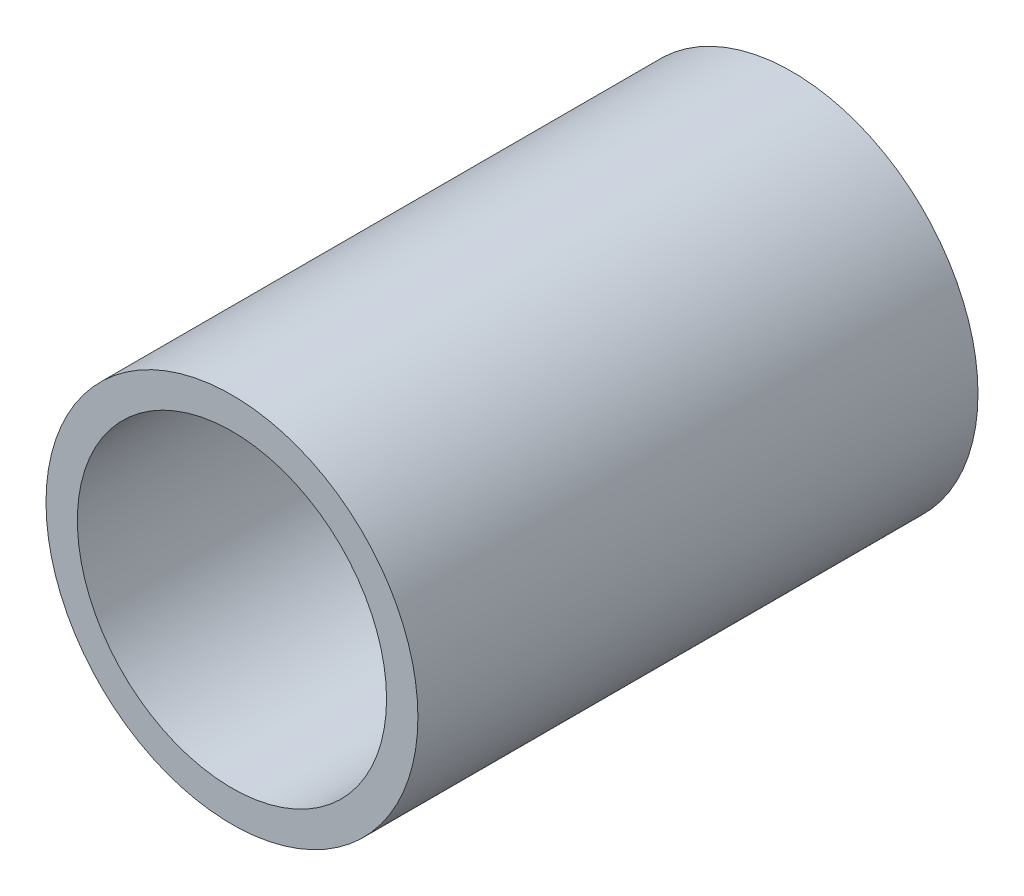
from build123d import *

# Parameters (mm, degrees)
SKETCH1_R           = 21.082
SKETCH1_R_2         = 17.526
BOSS_EXTRUDE1_DEPTH = 63.5


with BuildPart() as part:
    # Sketch1 → Boss-Extrude1 (new body)
    with BuildSketch(Plane.XY):
        Circle(SKETCH1_R)
        Circle(SKETCH1_R_2, mode=Mode.SUBTRACT)
    extrude(amount=BOSS_EXTRUDE1_DEPTH)


solid = part.part
